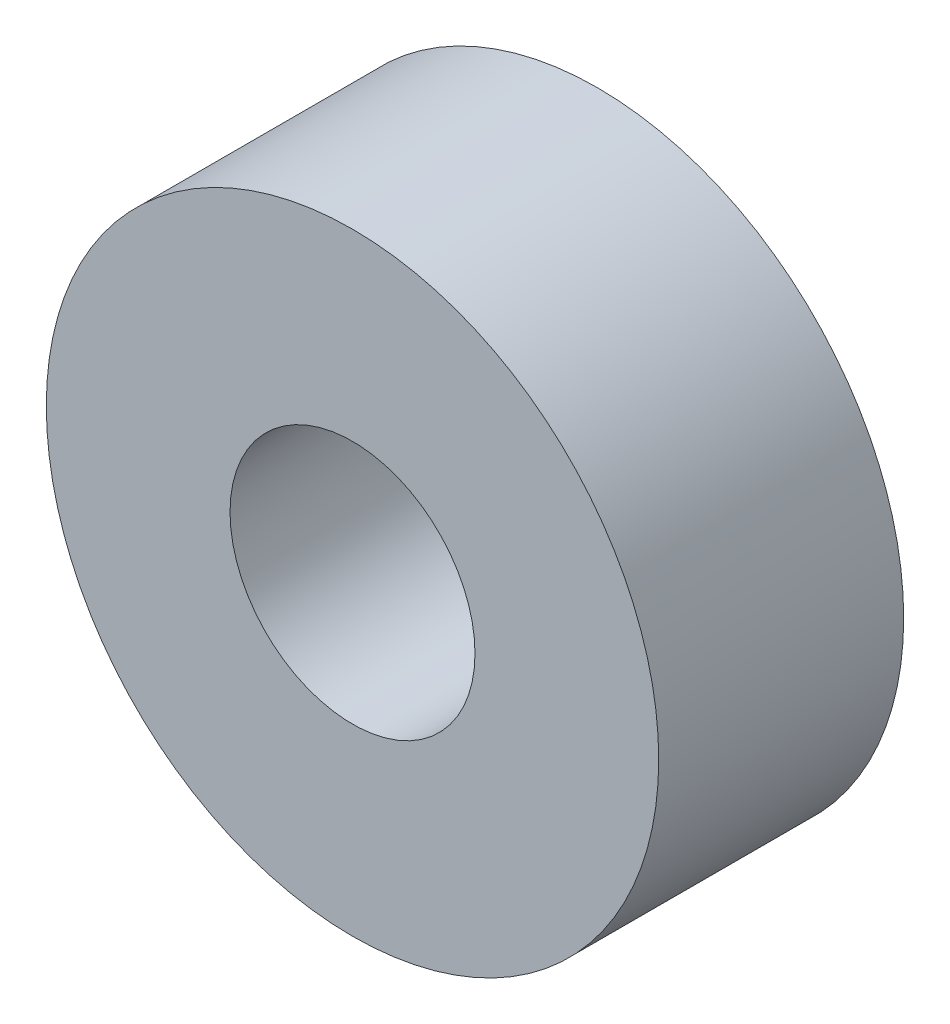
from build123d import *

# Parameters (mm, degrees)
SKETCH1_R           = 5
SKETCH1_R_2         = 2
BOSS_EXTRUDE1_DEPTH = 4


with BuildPart() as part:
    # Sketch1 → Boss-Extrude1 (new body)
    with BuildSketch(Plane.XY):
        Circle(SKETCH1_R)
        Circle(SKETCH1_R_2, mode=Mode.SUBTRACT)
    extrude(amount=BOSS_EXTRUDE1_DEPTH)


solid = part.part
